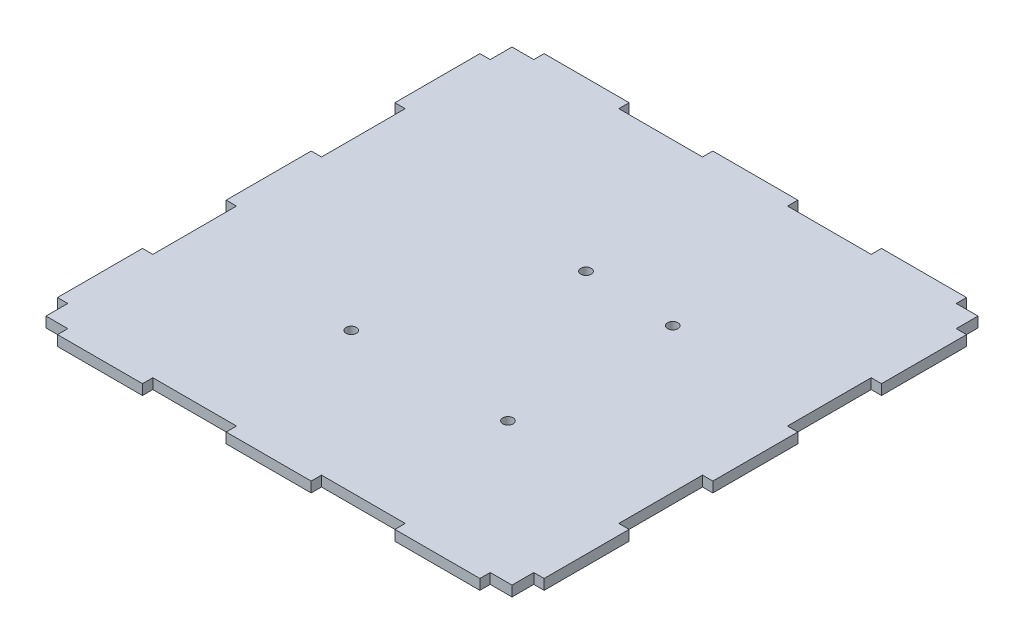
from build123d import *

# Parameters (mm, degrees)
SKETCH1_W                 = 150
SKETCH1_H                 = 150
BOSS_EXTRUDE1_DEPTH       = 3.18
SKETCH9_W                 = 3.18
SKETCH9_H                 = 9.9
SKETCH9_H_2               = 25.8
CUT_EXTRUDE7_DEPTH        = 10
MIRROR2_COPY_1_SKETCH_W   = 3.18
MIRROR2_COPY_1_SKETCH_H   = 9.9
MIRROR2_COPY_1_SKETCH_H_2 = 25.8
MIRROR2_COPY_1_DEPTH      = 10
SKETCH10_W                = 6.72
SKETCH10_H                = 3.18
SKETCH10_W_2              = 25.8
CUT_EXTRUDE8_DEPTH        = 10
MIRROR5_COPY_1_SKETCH_W   = 6.72
MIRROR5_COPY_1_SKETCH_H   = 3.18
MIRROR5_COPY_1_SKETCH_W_2 = 25.8
MIRROR5_COPY_1_DEPTH      = 10
SKETCH11_R                = 1.6
CUT_EXTRUDE9_DEPTH        = 10
SKETCH12_R                = 1.6
CUT_EXTRUDE10_DEPTH       = 10
SKETCH13_R                = 1.6
CUT_EXTRUDE11_DEPTH       = 10
SKETCH14_R                = 1.6
CUT_EXTRUDE12_DEPTH       = 10


with BuildPart() as part:
    # Sketch1 → Boss-Extrude1 (new body)
    with BuildSketch(Plane(origin=(0, 0, 0), x_dir=(1, 0, 0), z_dir=(0, 1, 0))):
        Rectangle(SKETCH1_W, SKETCH1_H)
    extrude(amount=BOSS_EXTRUDE1_DEPTH)

    # Sketch9 → Cut-Extrude7 (cut)
    with BuildSketch(Plane.XZ):
        with Locations((73.41, 70.05)):
            Rectangle(SKETCH9_W, SKETCH9_H)
        with Locations((73.41, 26)):
            Rectangle(SKETCH9_W, SKETCH9_H_2)
    cut_extrude7 = extrude(amount=-CUT_EXTRUDE7_DEPTH, mode=Mode.SUBTRACT)

    # Mirror1: Cut-Extrude7 across plane
    add(cut_extrude7.mirror(Plane.XY), mode=Mode.SUBTRACT)

    # Mirror2: Cut-Extrude7 across plane
    add(cut_extrude7.mirror(Plane(origin=(0, 0, 0), x_dir=(0, 0, 1), z_dir=(1, 0, 0))), mode=Mode.SUBTRACT)

    # Mirror2 copy 1 sketch → Mirror2 copy 1 (cut)
    with BuildSketch(Plane(origin=(0, 0, 0), x_dir=(-1, 0, 0), z_dir=(0, -1, 0))):
        with Locations((73.41, 70.05)):
            Rectangle(MIRROR2_COPY_1_SKETCH_W, MIRROR2_COPY_1_SKETCH_H)
        with Locations((73.41, 26)):
            Rectangle(MIRROR2_COPY_1_SKETCH_W, MIRROR2_COPY_1_SKETCH_H_2)
    extrude(amount=-MIRROR2_COPY_1_DEPTH, mode=Mode.SUBTRACT)

    # Sketch10 → Cut-Extrude8 (cut)
    with BuildSketch(Plane.XZ):
        with Locations((68.46, 73.41)):
            Rectangle(SKETCH10_W, SKETCH10_H)
        with Locations((26, 73.41)):
            Rectangle(SKETCH10_W_2, SKETCH10_H)
    cut_extrude8 = extrude(amount=-CUT_EXTRUDE8_DEPTH, mode=Mode.SUBTRACT)

    # Mirror4: Cut-Extrude8 across plane
    add(cut_extrude8.mirror(Plane(origin=(0, 0, 0), x_dir=(0, 0, 1), z_dir=(1, 0, 0))), mode=Mode.SUBTRACT)

    # Mirror5: Cut-Extrude8 across plane
    add(cut_extrude8.mirror(Plane.XY), mode=Mode.SUBTRACT)

    # Mirror5 copy 1 sketch → Mirror5 copy 1 (cut)
    with BuildSketch(Plane(origin=(0, 0, 0), x_dir=(-1, 0, 0), z_dir=(0, -1, 0))):
        with Locations((68.46, 73.41)):
            Rectangle(MIRROR5_COPY_1_SKETCH_W, MIRROR5_COPY_1_SKETCH_H)
        with Locations((26, 73.41)):
            Rectangle(MIRROR5_COPY_1_SKETCH_W_2, MIRROR5_COPY_1_SKETCH_H)
    extrude(amount=-MIRROR5_COPY_1_DEPTH, mode=Mode.SUBTRACT)

    # Sketch11 → Cut-Extrude9 (cut)
    with BuildSketch(Plane.XZ):
        with Locations((27.35, 28.6)):
            Circle(SKETCH11_R)
    extrude(amount=-CUT_EXTRUDE9_DEPTH, mode=Mode.SUBTRACT)

    # Sketch12 → Cut-Extrude10 (cut)
    with BuildSketch(Plane.XZ):
        with Locations((-20.95, 28.6)):
            Circle(SKETCH12_R)
    extrude(amount=-CUT_EXTRUDE10_DEPTH, mode=Mode.SUBTRACT)

    # Sketch13 → Cut-Extrude11 (cut)
    with BuildSketch(Plane.XZ):
        with Locations((27.35, -22.2)):
            Circle(SKETCH13_R)
    extrude(amount=-CUT_EXTRUDE11_DEPTH, mode=Mode.SUBTRACT)

    # Sketch14 → Cut-Extrude12 (cut)
    with BuildSketch(Plane.XZ):
        with Locations((-0.55, -23.360495604)):
            Circle(SKETCH14_R)
    extrude(amount=-CUT_EXTRUDE12_DEPTH, mode=Mode.SUBTRACT)


solid = part.part
